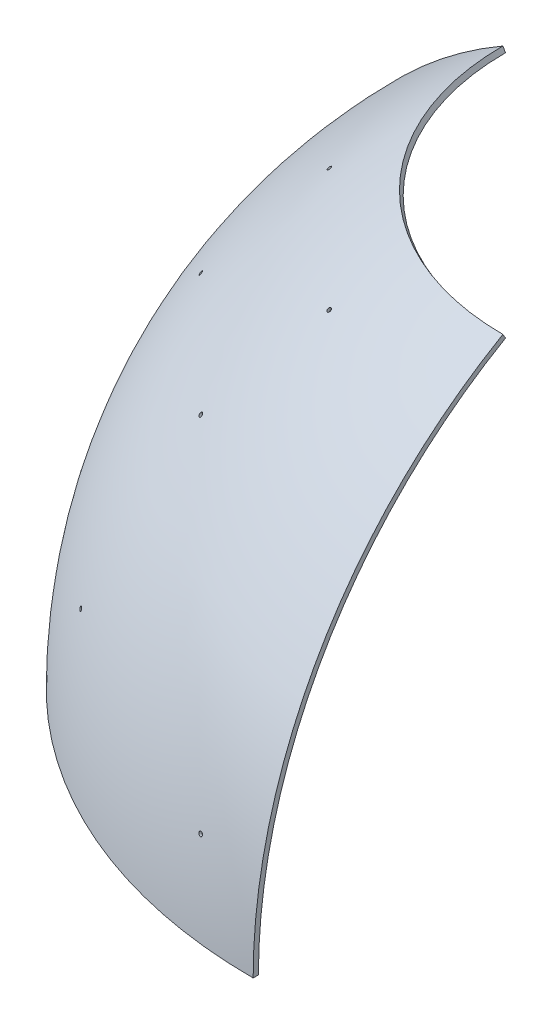
from build123d import *

# Parameters (mm, degrees)
REVOLVE1_ANGLE    = 90
CIRPATTERN3_COUNT = 2
CIRPATTERN3_ANGLE = 120


with BuildPart() as part:
    # Sketch1 → Revolve1 (revolve)
    with BuildSketch(Plane.XY):
        with BuildLine():
            ThreePointArc((-235, 0), (-203.515969889, 117.5), (-117.5, 203.515969889))
            Line((-117.5, 203.515969889), (-118.75, 205.681033399))
            ThreePointArc((-118.75, 205.681033399), (-205.681033399, 118.75), (-237.5, 0))
            Line((-237.5, 0), (-235, 0))
        make_face()
    revolve(axis=Axis((0, 0, 0), (0, 1, 0)), revolution_arc=REVOLVE1_ANGLE)

    # Sketch3 → Cut-Revolve1 (revolve, cut)
    with BuildSketch(Plane(origin=(0, 0, 0), x_dir=(0, 1, 0), z_dir=(0.9914448613738104, 0, 0.13052619222005188))):
        with BuildLine():
            ThreePointArc((40.807321752, 231.429821958), (42.283732139, 231.16462964), (43.758419697, 230.890018636))
            Line((43.758419697, 230.890018636), (43.975497515, 232.121128117))
            ThreePointArc((43.975497515, 232.121128117), (42.992545036, 232.305194887), (42.008822216, 232.485099213))
            Line((42.008822216, 232.485099213), (42.225884372, 233.716119874))
            ThreePointArc((42.225884372, 233.716119874), (41.733755769, 233.804498736), (41.241442196, 233.89184134))
            Line((41.241442196, 233.89184134), (40.807321752, 231.429821958))
        make_face()
    cut_revolve1 = revolve(axis=Axis((0, 0, 0), (-0.12854320606946884, 0.17364817766693075, 0.9763825861650424)), mode=Mode.SUBTRACT)

    # Mirror2: Cut-Revolve1 across plane
    add(cut_revolve1.mirror(Plane(origin=(0, 0, 0), x_dir=(-0.28867513459481386, 0.4082482904638622, 0.8660254037844386), z_dir=(-0.5000000000000019, 0.7071067811865464, -0.4999999999999999))), mode=Mode.SUBTRACT)

    # CirPattern3: Cut-Revolve1 ×2 about axis
    cirpattern3_axis = Axis((0, -50, -70.710678119), (0, -0.5773502691896264, -0.8164965809277257))
    for i in range(1, CIRPATTERN3_COUNT):
        add(cut_revolve1.rotate(cirpattern3_axis, i * CIRPATTERN3_ANGLE / (CIRPATTERN3_COUNT - 1)), mode=Mode.SUBTRACT)

    # Mirror5: Cut-Revolve1 across plane
    add(cut_revolve1.mirror(Plane(origin=(0, 0, 0), x_dir=(-0.7071067811865489, 0, 0.7071067811865462), z_dir=(0.7071067811865464, 0, 0.7071067811865488))), mode=Mode.SUBTRACT)

    # Mirror5 copy 1 sketch → Mirror5 copy 1 (revolve, cut)
    with BuildSketch(Plane(origin=(0, 0, 0), x_dir=(-0.707106781186544, 3.3306690738754696e-15, -0.7071067811865517), z_dir=(0.43045933457688246, 0.7933533402912366, -0.43045933457687385))):
        with BuildLine():
            ThreePointArc((40.807321752, 231.429821958), (42.283732139, 231.16462964), (43.758419697, 230.890018636))
            Line((43.758419697, 230.890018636), (43.975497515, 232.121128117))
            ThreePointArc((43.975497515, 232.121128117), (42.992545036, 232.305194887), (42.008822216, 232.485099213))
            Line((42.008822216, 232.485099213), (42.225884372, 233.716119874))
            ThreePointArc((42.225884372, 233.716119874), (41.733755769, 233.804498736), (41.241442196, 233.89184134))
            Line((41.241442196, 233.89184134), (40.807321752, 231.429821958))
        make_face()
    revolve(axis=Axis((0, 0, 0), (-0.6752507000862306, 0.5995129750225779, 0.42967509214828115)), mode=Mode.SUBTRACT)

    # Mirror5 copy 2 sketch → Mirror5 copy 2 (revolve, cut)
    with BuildSketch(Plane(origin=(0, 0, 0), x_dir=(-0.7071067811865479, -1.887379141862766e-15, -0.7071067811865478), z_dir=(-0.5609855267969319, -0.6087614290087177, 0.5609855267969336))):
        with BuildLine():
            ThreePointArc((40.807321752, -231.429821958), (42.283732139, -231.16462964), (43.758419697, -230.890018636))
            Line((43.758419697, -230.890018636), (43.975497515, -232.121128117))
            ThreePointArc((43.975497515, -232.121128117), (42.992545036, -232.305194887), (42.008822216, -232.485099213))
            Line((42.008822216, -232.485099213), (42.225884372, -233.716119874))
            ThreePointArc((42.225884372, -233.716119874), (41.733755769, -233.804498736), (41.241442196, -233.89184134))
            Line((41.241442196, -233.89184134), (40.807321752, -231.429821958))
        make_face()
    revolve(axis=Axis((0, 0, 0), (0.5467074940167592, -0.7813005203969431, -0.3011318860788107)), mode=Mode.SUBTRACT)

    # Sketch7 → Cut-Revolve2 (revolve, cut)
    with BuildSketch(Plane(origin=(0, 0, 0), x_dir=(0, 1, 0), z_dir=(0.819152044288991, 0, 0.5735764363510473))):
        with BuildLine():
            ThreePointArc((60.822475599, 226.992569178), (62.270154766, 226.599708353), (63.715296767, 226.197614837))
            Line((63.715296767, 226.197614837), (64.038846799, 227.405119997))
            ThreePointArc((64.038846799, 227.405119997), (63.075677226, 227.67415629), (62.111377464, 227.939113119))
            Line((62.111377464, 227.939113119), (62.434904154, 229.146531161))
            ThreePointArc((62.434904154, 229.146531161), (61.952350974, 229.277465549), (61.469523212, 229.407383744))
            Line((61.469523212, 229.407383744), (60.822475599, 226.992569178))
        make_face()
    cut_revolve2 = revolve(axis=Axis((0, 0, 0), (-0.5540322932223244, 0.25881904510252146, 0.791240115236223)), mode=Mode.SUBTRACT)

    # Mirror6: Cut-Revolve2 across plane
    add(cut_revolve2.mirror(Plane(origin=(0, 0, 0), x_dir=(-0.7071067811865489, 0, 0.7071067811865462), z_dir=(0.7071067811865464, 0, 0.7071067811865488))), mode=Mode.SUBTRACT)


solid = part.part
